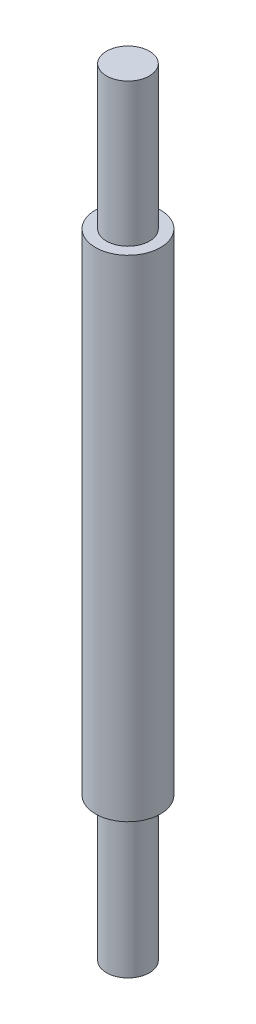
from build123d import *

# Parameters (mm, degrees)
SKETCH2_R           = 4.039553008
BOSS_EXTRUDE1_DEPTH = 60.96
SKETCH6_R           = 2.667
BOSS_EXTRUDE2_DEPTH = 17.78
SKETCH5_R           = 2.667
BOSS_EXTRUDE3_DEPTH = 17.78


with BuildPart() as part:
    # Sketch2 → Boss-Extrude1 (new body)
    with BuildSketch(Plane(origin=(0, 0, 0), x_dir=(1, 0, 0), z_dir=(0, 1, 0))):
        Circle(SKETCH2_R)
    extrude(amount=BOSS_EXTRUDE1_DEPTH)

    # Sketch6 → Boss-Extrude2 (add)
    with BuildSketch(Plane(origin=(0, 60.96, 0), x_dir=(1, 0, 0), z_dir=(0, 1, 0))):
        Circle(SKETCH6_R)
    extrude(amount=BOSS_EXTRUDE2_DEPTH)

    # Sketch5 → Boss-Extrude3 (add)
    with BuildSketch(Plane(origin=(0, 0, 0), x_dir=(-1, 0, 0), z_dir=(0, -1, 0))):
        Circle(SKETCH5_R)
    extrude(amount=BOSS_EXTRUDE3_DEPTH)


solid = part.part
